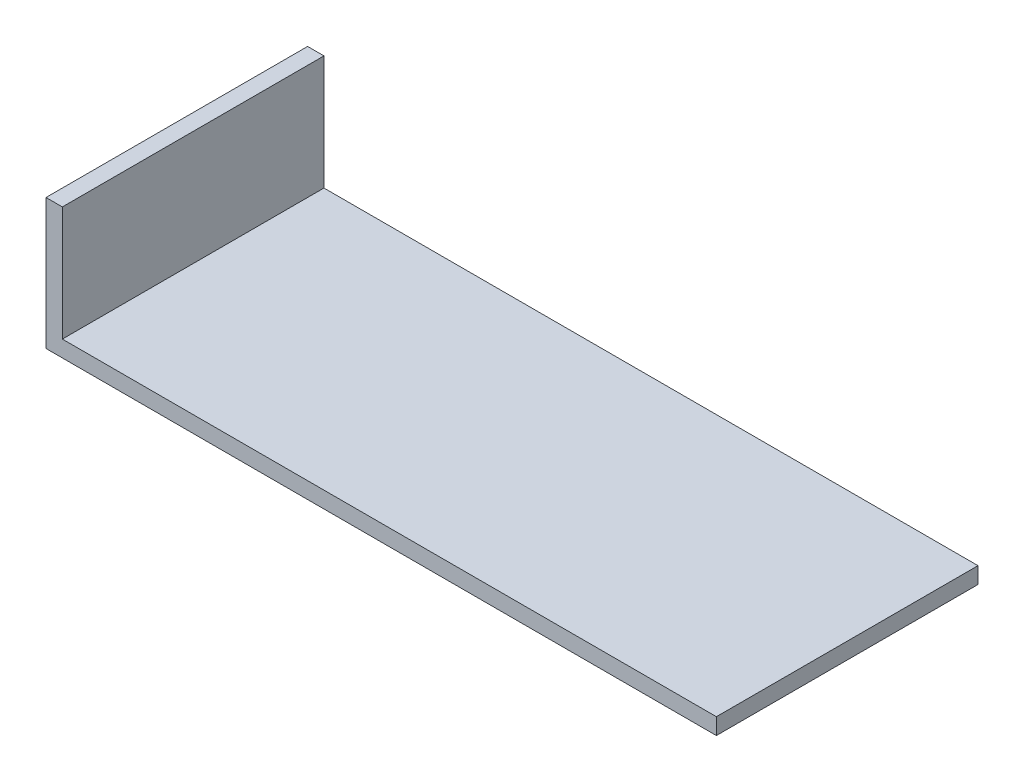
from build123d import *

# Parameters (mm, degrees)
BOSS_EXTRUDE1_DEPTH = 50.8


with BuildPart() as part:
    # Sketch1 → Boss-Extrude1 (new body)
    with BuildSketch(Plane.XY):
        Polygon((0, 0), (130.175, 0), (130.175, 3.175), (3.175, 3.175), (3.175, 25.4), (0, 25.4), align=None)
    extrude(amount=BOSS_EXTRUDE1_DEPTH)


solid = part.part
